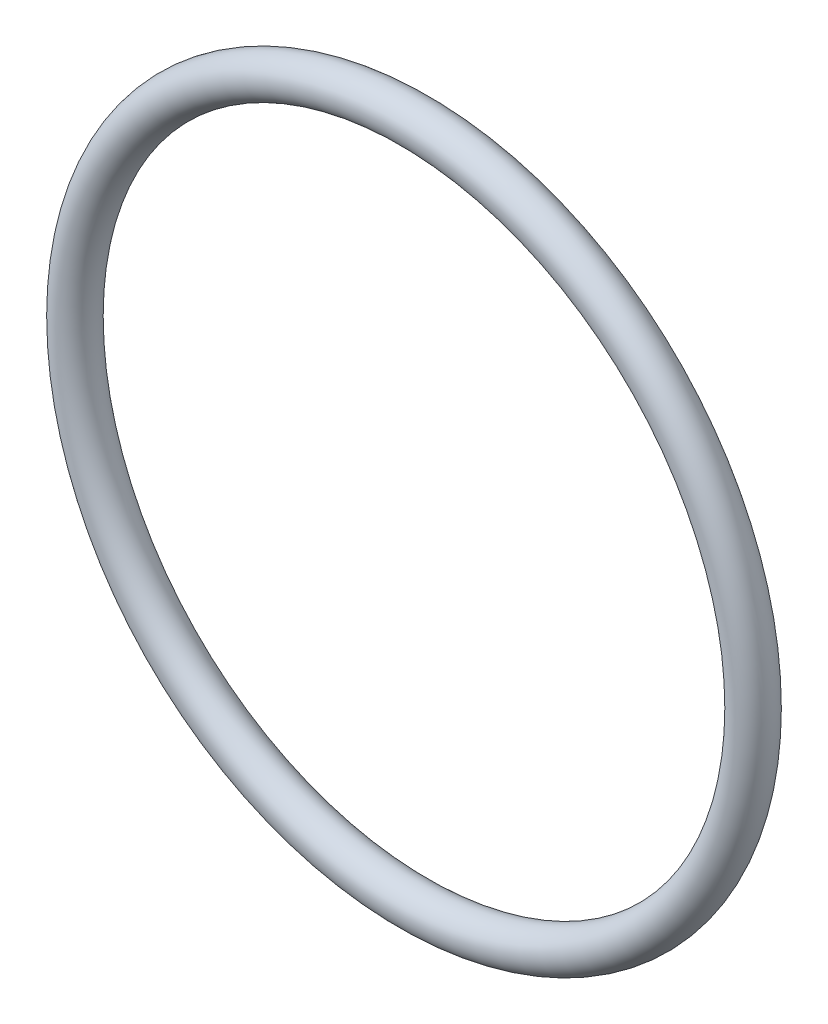
from build123d import *

# Parameters (mm, degrees)
SKETCH1_R = 2.667


with BuildPart() as part:
    # Sketch1 → Revolve1 (revolve)
    with BuildSketch(Plane(origin=(0, 0, 0), x_dir=(0, -1, 0), z_dir=(1, 0, 0))):
        with Locations((45.212, 0)):
            Circle(SKETCH1_R)
    revolve(axis=Axis((0, 0, 2.667), (0, 0, -1)))


solid = part.part
